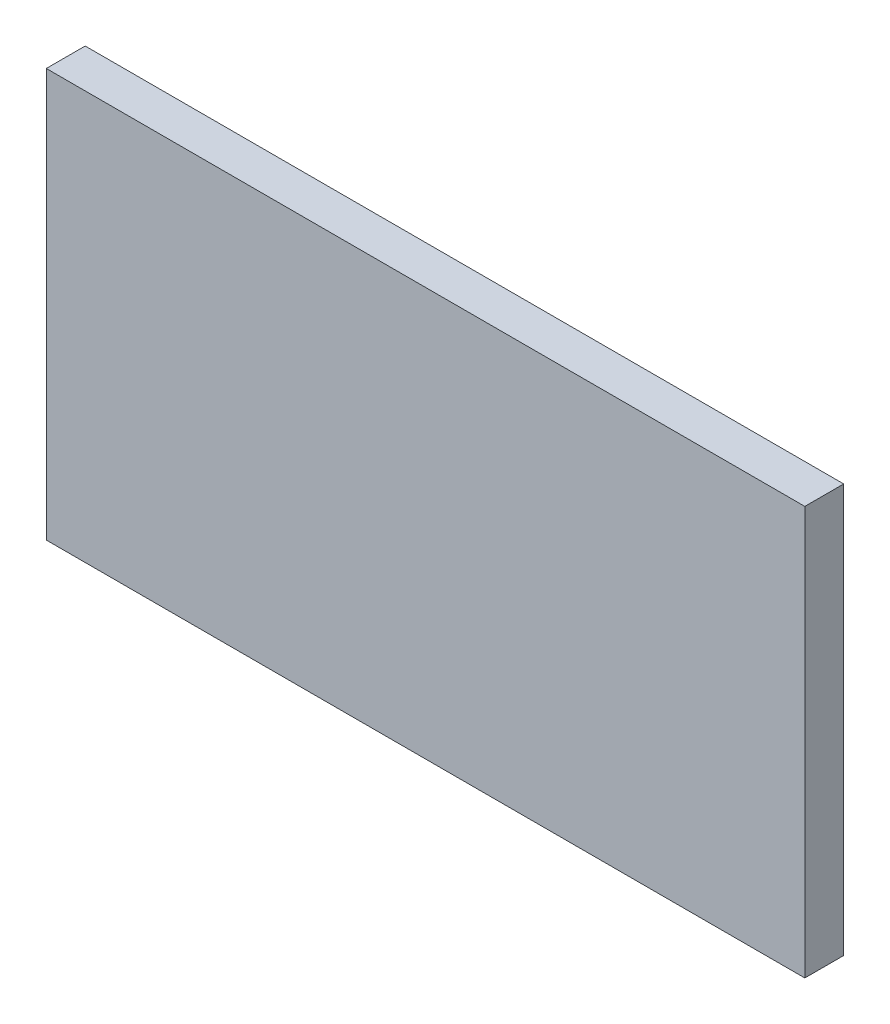
from build123d import *

# Parameters (mm, degrees)
SKETCH1_W           = 123.825
SKETCH1_H           = 66.675
BOSS_EXTRUDE1_DEPTH = 6.35


with BuildPart() as part:
    # Sketch1 → Boss-Extrude1 (new body)
    with BuildSketch(Plane.XY):
        with Locations((11.1125, -1.5875)):
            Rectangle(SKETCH1_W, SKETCH1_H)
    extrude(amount=BOSS_EXTRUDE1_DEPTH)


solid = part.part
